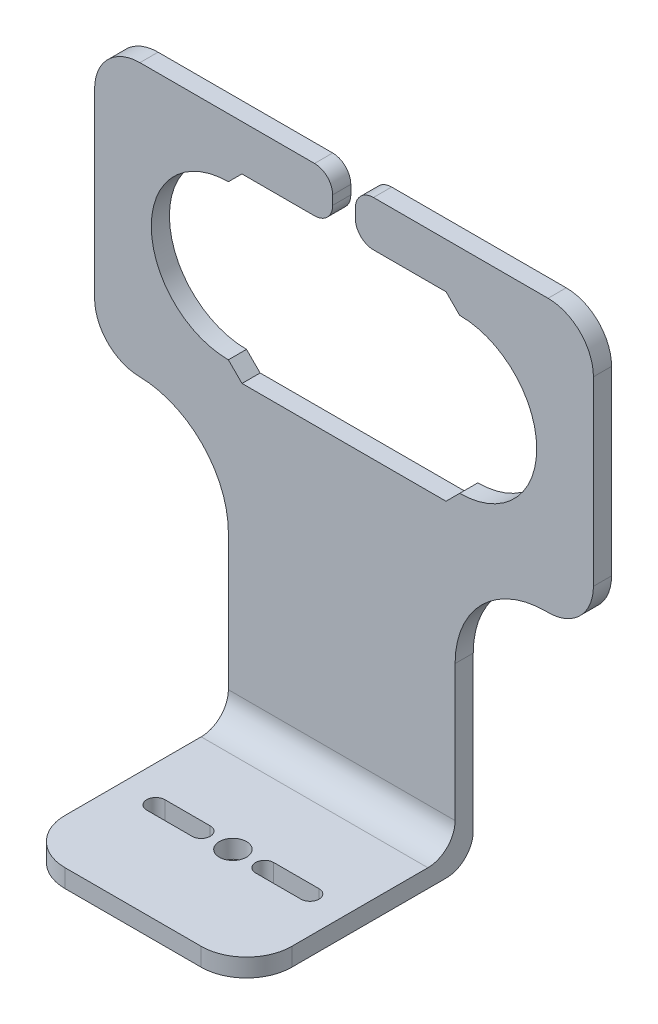
from build123d import *

# Parameters (mm, degrees)
BOSS_EXTRUDE1_DEPTH = 2
SKETCH2_W           = 25
SKETCH2_H           = 2
BOSS_EXTRUDE2_DEPTH = 23
FILLET1_R           = 3
FILLET2_R           = 10
FILLET3_R           = 5
SKETCH3_R           = 1.5
CUT_EXTRUDE1_DEPTH  = 2


with BuildPart() as part:
    # Sketch1 → Boss-Extrude1 (new body)
    with BuildSketch(Plane.XY):
        with BuildLine():
            Line((-1.333510856, 27.908436521), (-1.333510856, 26.904337049))
            ThreePointArc((-1.333510856, 26.904337049), (-1.919297294, 25.490123487), (-3.333510856, 24.904337049))
            Line((-3.333510856, 24.904337049), (-11.337610328, 24.904337049))
            Line((-11.337610328, 24.904337049), (-12.833510856, 23.408436521))
            ThreePointArc((-12.833510856, 23.408436521), (-21.333510856, 14.908436521), (-12.833510856, 6.408436521))
            Line((-12.833510856, 6.408436521), (-11.329411385, 4.904337049))
            Line((-11.329411385, 4.904337049), (11.162389672, 4.904337049))
            Line((11.162389672, 4.904337049), (12.666489144, 6.408436521))
            ThreePointArc((12.666489144, 6.408436521), (21.166489144, 14.908436521), (12.666489144, 23.408436521))
            Line((12.666489144, 23.408436521), (11.170588615, 24.904337049))
            Line((11.170588615, 24.904337049), (3.166489144, 24.904337049))
            ThreePointArc((3.166489144, 24.904337049), (1.752275581, 25.490123487), (1.166489144, 26.904337049))
            Line((1.166489144, 26.904337049), (1.166489144, 27.908436521))
            ThreePointArc((1.166489144, 27.908436521), (1.752275581, 29.322650083), (3.166489144, 29.908436521))
            Line((3.166489144, 29.908436521), (22.416489144, 29.908436521))
            ThreePointArc((22.416489144, 29.908436521), (25.95202305, 28.443970427), (27.416489144, 24.908436521))
            Line((27.416489144, 24.908436521), (27.416489144, 4.904337049))
            ThreePointArc((27.416489144, 4.904337049), (25.95202305, 1.368803144), (22.416489144, -0.095662951))
            Line((22.416489144, -0.095662951), (12.166489144, -0.095662951))
            Line((12.166489144, -0.095662951), (12.166489144, -30.091563479))
            Line((12.166489144, -30.091563479), (-12.833510856, -30.091563479))
            Line((-12.833510856, -30.091563479), (-12.833510856, -0.095662951))
            Line((-12.833510856, -0.095662951), (-22.583510856, -0.095662951))
            ThreePointArc((-22.583510856, -0.095662951), (-26.119044762, 1.368803144), (-27.583510856, 4.904337049))
            Line((-27.583510856, 4.904337049), (-27.583510856, 24.908436521))
            ThreePointArc((-27.583510856, 24.908436521), (-26.119044762, 28.443970427), (-22.583510856, 29.908436521))
            Line((-22.583510856, 29.908436521), (-3.333510856, 29.908436521))
            ThreePointArc((-3.333510856, 29.908436521), (-1.919297294, 29.322650083), (-1.333510856, 27.908436521))
        make_face()
    extrude(amount=-BOSS_EXTRUDE1_DEPTH)

    # Sketch2 → Boss-Extrude2 (add)
    with BuildSketch(Plane.XY):
        with Locations((-0.333510856, -29.091563479)):
            Rectangle(SKETCH2_W, SKETCH2_H)
    extrude(amount=BOSS_EXTRUDE2_DEPTH)

    # Fillet1
    fillet1_edges = [part.edges().sort_by_distance(p)[0] for p in [
        (-0.333510856, -30.091563479, -2),
        (-0.333510856, -28.091563479, 0),
    ]]
    fillet(fillet1_edges, radius=FILLET1_R)

    # Fillet2
    fillet2_edges = [part.edges().sort_by_distance(p)[0] for p in [
        (-12.833510856, -0.095662951, -1),
        (12.166489144, -0.095662951, -1),
    ]]
    fillet(fillet2_edges, radius=FILLET2_R)

    # Fillet3
    fillet3_edges = [part.edges().sort_by_distance(p)[0] for p in [
        (-12.833510856, -29.091563479, 23),
        (12.166489144, -29.091563479, 23),
    ]]
    fillet(fillet3_edges, radius=FILLET3_R)

    # Sketch3 → Cut-Extrude1 (cut)
    with BuildSketch(Plane.XZ.offset(30.091563479)):
        with Locations((-0.333510856, 12)):
            Circle(SKETCH3_R)
        with BuildLine():
            Line((3.166489144, 11), (8.166489144, 11))
            ThreePointArc((8.166489144, 11), (9.166489144, 12), (8.166489144, 13))
            Line((8.166489144, 13), (3.166489144, 13))
            ThreePointArc((3.166489144, 13), (2.166489144, 12), (3.166489144, 11))
        make_face()
        with BuildLine():
            Line((-3.833510856, 13), (-8.833510856, 13))
            ThreePointArc((-8.833510856, 13), (-9.833510856, 12), (-8.833510856, 11))
            Line((-8.833510856, 11), (-3.833510856, 11))
            ThreePointArc((-3.833510856, 11), (-2.833510856, 12), (-3.833510856, 13))
        make_face()
    extrude(amount=-CUT_EXTRUDE1_DEPTH, mode=Mode.SUBTRACT)


solid = part.part
